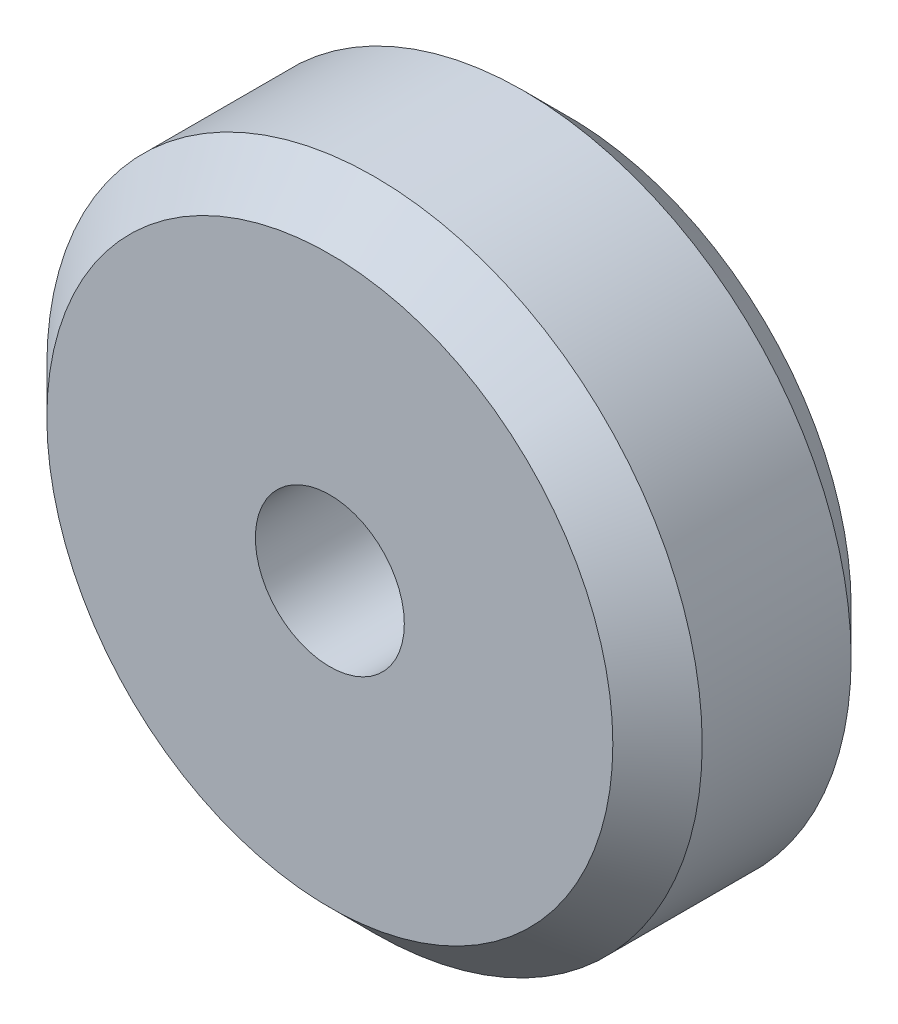
from build123d import *

# Parameters (mm, degrees)
SKETCH1_R           = 11
SKETCH1_R_2         = 2.5
BOSS_EXTRUDE1_DEPTH = 4
CHAMFER3_SIZE       = 1.5


with BuildPart() as part:
    # Sketch1 → Boss-Extrude1 (new body, symmetric)
    with BuildSketch(Plane.XY):
        Circle(SKETCH1_R)
        Circle(SKETCH1_R_2, mode=Mode.SUBTRACT)
    extrude(amount=BOSS_EXTRUDE1_DEPTH, both=True)

    # Chamfer3
    chamfer3_edges = [part.edges().sort_by_distance(p)[0] for p in [
        (-11, 0, -4),
        (-11, 0, 4),
    ]]
    chamfer(chamfer3_edges, length=CHAMFER3_SIZE)


solid = part.part
